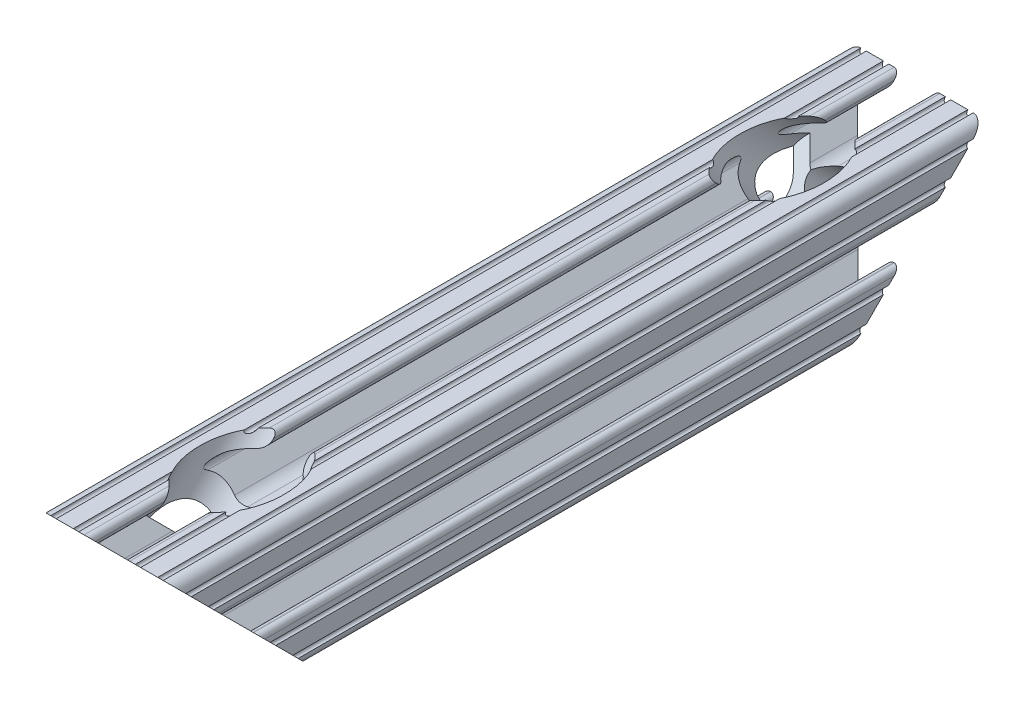
from build123d import *

# Parameters (mm, degrees)
SKETCH1_R               = 2.6035
BOSS_EXTRUDE1_DEPTH     = 76.2
CUT_EXTRUDE1_DEPTH      = 79.288057838
CUT_EXTRUDE1_DEPTH_BACK = 79.288057838
CUT_REVOLVE1_ANGLE      = 360


with BuildPart() as part:
    # Sketch1 → Boss-Extrude1 (new, symmetric)
    with BuildSketch(Plane.XY):
        with BuildLine():
            Line((-7.179650497, -8.645192506), (-3.952270251, -5.423690499))
            ThreePointArc((-3.952270251, -5.423690499), (-2.922936451, -4.736929036), (-1.709253557, -4.4958))
            Line((-1.709253557, -4.4958), (1.709253557, -4.4958))
            ThreePointArc((1.709253557, -4.4958), (2.922936451, -4.736929036), (3.952270251, -5.423690499))
            Line((3.952270251, -5.423690499), (7.179650497, -8.645192506))
            ThreePointArc((7.179650497, -8.645192506), (7.41473083, -9.822813117), (6.416408329, -10.4902))
            Line((6.416408329, -10.4902), (4.287512407, -10.4902))
            ThreePointArc((4.287512407, -10.4902), (3.54574862, -10.79744862), (3.2385, -11.539212407))
            Line((3.2385, -11.539212407), (3.2385, -11.650987593))
            ThreePointArc((3.2385, -11.650987593), (3.54574862, -12.39275138), (4.287512407, -12.7))
            Line((4.287512407, -12.7), (5.317126718, -12.7))
            ThreePointArc((5.317126718, -12.7), (5.825126718, -12.192), (6.333126718, -12.7))
            Line((6.333126718, -12.7), (9.550443118, -12.7))
            ThreePointArc((9.550443118, -12.7), (10.058366869, -12.192000006), (10.566443095, -12.699847501))
            ThreePointArc((10.566443095, -12.699847501), (12.082537762, -12.08250727), (12.699846982, -10.566399977))
            ThreePointArc((12.699846982, -10.566399977), (12.192000006, -10.058323491), (12.7, -9.5504))
            Line((12.7, -9.5504), (12.7, -6.3330836))
            ThreePointArc((12.7, -6.3330836), (12.192, -5.8250836), (12.7, -5.3170836))
            Line((12.7, -5.3170836), (12.7, -4.287469289))
            ThreePointArc((12.7, -4.287469289), (12.39275138, -3.545705502), (11.650987593, -3.238456882))
            Line((11.650987593, -3.238456882), (11.539212407, -3.238456882))
            ThreePointArc((11.539212407, -3.238456882), (10.79744862, -3.545705502), (10.4902, -4.287469289))
            Line((10.4902, -4.287469289), (10.4902, -6.402089023))
            ThreePointArc((10.4902, -6.402089023), (9.856505071, -7.351067942), (8.737131347, -7.129408934))
            Line((8.737131347, -7.129408934), (5.441005833, -3.840816462))
            ThreePointArc((5.441005833, -3.840816462), (4.750877967, -2.809883091), (4.5085, -1.593185507))
            Line((4.5085, -1.593185507), (4.5085, 1.593185507))
            ThreePointArc((4.5085, 1.593185507), (4.750877967, 2.809883091), (5.441005833, 3.840816462))
            Line((5.441005833, 3.840816462), (8.737131347, 7.129408934))
            ThreePointArc((8.737131347, 7.129408934), (9.856505071, 7.351067942), (10.4902, 6.402089023))
            Line((10.4902, 6.402089023), (10.4902, 4.287469289))
            ThreePointArc((10.4902, 4.287469289), (10.79744862, 3.545705502), (11.539212407, 3.238456882))
            Line((11.539212407, 3.238456882), (11.650987593, 3.238456882))
            ThreePointArc((11.650987593, 3.238456882), (12.39275138, 3.545705502), (12.7, 4.287469289))
            Line((12.7, 4.287469289), (12.7, 5.3170836))
            ThreePointArc((12.7, 5.3170836), (12.192, 5.8250836), (12.7, 6.3330836))
            Line((12.7, 6.3330836), (12.7, 9.5504))
            ThreePointArc((12.7, 9.5504), (12.192000006, 10.058323491), (12.699846982, 10.566399977))
            ThreePointArc((12.699846982, 10.566399977), (12.082537762, 12.08250727), (10.566443095, 12.699847501))
            ThreePointArc((10.566443095, 12.699847501), (10.058366869, 12.192000006), (9.550443118, 12.7))
            Line((9.550443118, 12.7), (6.333126718, 12.7))
            ThreePointArc((6.333126718, 12.7), (5.825126718, 12.192), (5.317126718, 12.7))
            Line((5.317126718, 12.7), (4.287512407, 12.7))
            ThreePointArc((4.287512407, 12.7), (3.54574862, 12.39275138), (3.2385, 11.650987593))
            Line((3.2385, 11.650987593), (3.2385, 11.539212407))
            ThreePointArc((3.2385, 11.539212407), (3.54574862, 10.79744862), (4.287512407, 10.4902))
            Line((4.287512407, 10.4902), (6.476788598, 10.4902))
            ThreePointArc((6.476788598, 10.4902), (7.432222385, 9.85140422), (7.207036008, 8.724370562))
            Line((7.207036008, 8.724370562), (3.898272566, 5.423169045))
            ThreePointArc((3.898272566, 5.423169045), (2.869120213, 4.736787962), (1.655778399, 4.4958))
            Line((1.655778399, 4.4958), (-1.655778399, 4.4958))
            ThreePointArc((-1.655778399, 4.4958), (-2.869120213, 4.736787962), (-3.898272566, 5.423169045))
            Line((-3.898272566, 5.423169045), (-7.207036008, 8.724370562))
            ThreePointArc((-7.207036008, 8.724370562), (-7.432222385, 9.85140422), (-6.476788598, 10.4902))
            Line((-6.476788598, 10.4902), (-4.287512407, 10.4902))
            ThreePointArc((-4.287512407, 10.4902), (-3.54574862, 10.79744862), (-3.2385, 11.539212407))
            Line((-3.2385, 11.539212407), (-3.2385, 11.650987593))
            ThreePointArc((-3.2385, 11.650987593), (-3.54574862, 12.39275138), (-4.287512407, 12.7))
            Line((-4.287512407, 12.7), (-5.317126718, 12.7))
            ThreePointArc((-5.317126718, 12.7), (-5.825126718, 12.192), (-6.333126718, 12.7))
            Line((-6.333126718, 12.7), (-9.550443118, 12.7))
            ThreePointArc((-9.550443118, 12.7), (-10.058366869, 12.192000006), (-10.566443095, 12.699847501))
            ThreePointArc((-10.566443095, 12.699847501), (-12.082537762, 12.08250727), (-12.699846982, 10.566399977))
            ThreePointArc((-12.699846982, 10.566399977), (-12.192000006, 10.058323491), (-12.7, 9.5504))
            Line((-12.7, 9.5504), (-12.7, 6.3330836))
            ThreePointArc((-12.7, 6.3330836), (-12.192, 5.8250836), (-12.7, 5.3170836))
            Line((-12.7, 5.3170836), (-12.7, 4.287469289))
            ThreePointArc((-12.7, 4.287469289), (-12.39275138, 3.545705502), (-11.650987593, 3.238456882))
            Line((-11.650987593, 3.238456882), (-11.539212407, 3.238456882))
            ThreePointArc((-11.539212407, 3.238456882), (-10.79744862, 3.545705502), (-10.4902, 4.287469289))
            Line((-10.4902, 4.287469289), (-10.4902, 6.402089023))
            ThreePointArc((-10.4902, 6.402089023), (-9.856505071, 7.351067942), (-8.737131347, 7.129408934))
            Line((-8.737131347, 7.129408934), (-5.441005833, 3.840816462))
            ThreePointArc((-5.441005833, 3.840816462), (-4.750877967, 2.809883091), (-4.5085, 1.593185507))
            Line((-4.5085, 1.593185507), (-4.5085, -1.593185507))
            ThreePointArc((-4.5085, -1.593185507), (-4.750877967, -2.809883091), (-5.441005833, -3.840816462))
            Line((-5.441005833, -3.840816462), (-8.737131347, -7.129408934))
            ThreePointArc((-8.737131347, -7.129408934), (-9.856505071, -7.351067942), (-10.4902, -6.402089023))
            Line((-10.4902, -6.402089023), (-10.4902, -4.287469289))
            ThreePointArc((-10.4902, -4.287469289), (-10.79744862, -3.545705502), (-11.539212407, -3.238456882))
            Line((-11.539212407, -3.238456882), (-11.650987593, -3.238456882))
            ThreePointArc((-11.650987593, -3.238456882), (-12.39275138, -3.545705502), (-12.7, -4.287469289))
            Line((-12.7, -4.287469289), (-12.7, -5.3170836))
            ThreePointArc((-12.7, -5.3170836), (-12.192, -5.8250836), (-12.7, -6.3330836))
            Line((-12.7, -6.3330836), (-12.7, -9.5504))
            ThreePointArc((-12.7, -9.5504), (-12.192000006, -10.058323491), (-12.699846982, -10.566399977))
            ThreePointArc((-12.699846982, -10.566399977), (-12.082537762, -12.08250727), (-10.566443095, -12.699847501))
            ThreePointArc((-10.566443095, -12.699847501), (-10.058366869, -12.192000006), (-9.550443118, -12.7))
            Line((-9.550443118, -12.7), (-6.333126718, -12.7))
            ThreePointArc((-6.333126718, -12.7), (-5.825126718, -12.192), (-5.317126718, -12.7))
            Line((-5.317126718, -12.7), (-4.287512407, -12.7))
            ThreePointArc((-4.287512407, -12.7), (-3.54574862, -12.39275138), (-3.2385, -11.650987593))
            Line((-3.2385, -11.650987593), (-3.2385, -11.539212407))
            ThreePointArc((-3.2385, -11.539212407), (-3.54574862, -10.79744862), (-4.287512407, -10.4902))
            Line((-4.287512407, -10.4902), (-6.416408329, -10.4902))
            ThreePointArc((-6.416408329, -10.4902), (-7.41473083, -9.822813117), (-7.179650497, -8.645192506))
        make_face()
        with Locations(Location((0, 0, 0), (0, 0, 180))):
            Circle(SKETCH1_R, mode=Mode.SUBTRACT)
    extrude(amount=BOSS_EXTRUDE1_DEPTH, both=True)

    # Sketch2 → Cut-Extrude1 (cut, two sides)
    with BuildSketch(Plane(origin=(0, 0, 0), x_dir=(0, 0, -1), z_dir=(1, 0, 0))) as cut_extrude1_sk:
        Polygon((-76.2, 12.699847501), (-76.2, -12.7), (-50.800152499, -12.7), align=None)
        Polygon((50.800152499, -12.7), (76.2, 12.699847501), (76.2, -12.7), align=None)
    extrude(amount=CUT_EXTRUDE1_DEPTH, mode=Mode.SUBTRACT)
    extrude(cut_extrude1_sk.sketch, amount=-CUT_EXTRUDE1_DEPTH_BACK, mode=Mode.SUBTRACT)

    # Sketch3 → Cut-Revolve1 (revolve, symmetric, cut)
    with BuildSketch(Plane(origin=(0, 0, 0), x_dir=(0, 0, -1), z_dir=(1, 0, 0))) as cut_revolve1_sk:
        Polygon((-45.187644922, 18.312507577), (-63.500152499, 0), (-65.808078322, 2.307925823), (-61.317950261, 6.798053884), (-64.622684514, 10.102788136), (-50.800304998, 23.925167653), align=None)
    cut_revolve1 = revolve(axis=Axis((0, 0, 63.500152499), (0, -0.7071067811865477, 0.7071067811865475)), revolution_arc=CUT_REVOLVE1_ANGLE / 2, mode=Mode.SUBTRACT)
    cut_revolve1 = cut_revolve1 + revolve(cut_revolve1_sk.sketch, axis=Axis((0, 0, 63.500152499), (0, 0.7071067811865477, -0.7071067811865475)), revolution_arc=CUT_REVOLVE1_ANGLE / 2, mode=Mode.SUBTRACT)

    # Mirror1: Cut-Revolve1 across plane
    add(cut_revolve1.mirror(Plane.XY), mode=Mode.SUBTRACT)


solid = part.part
